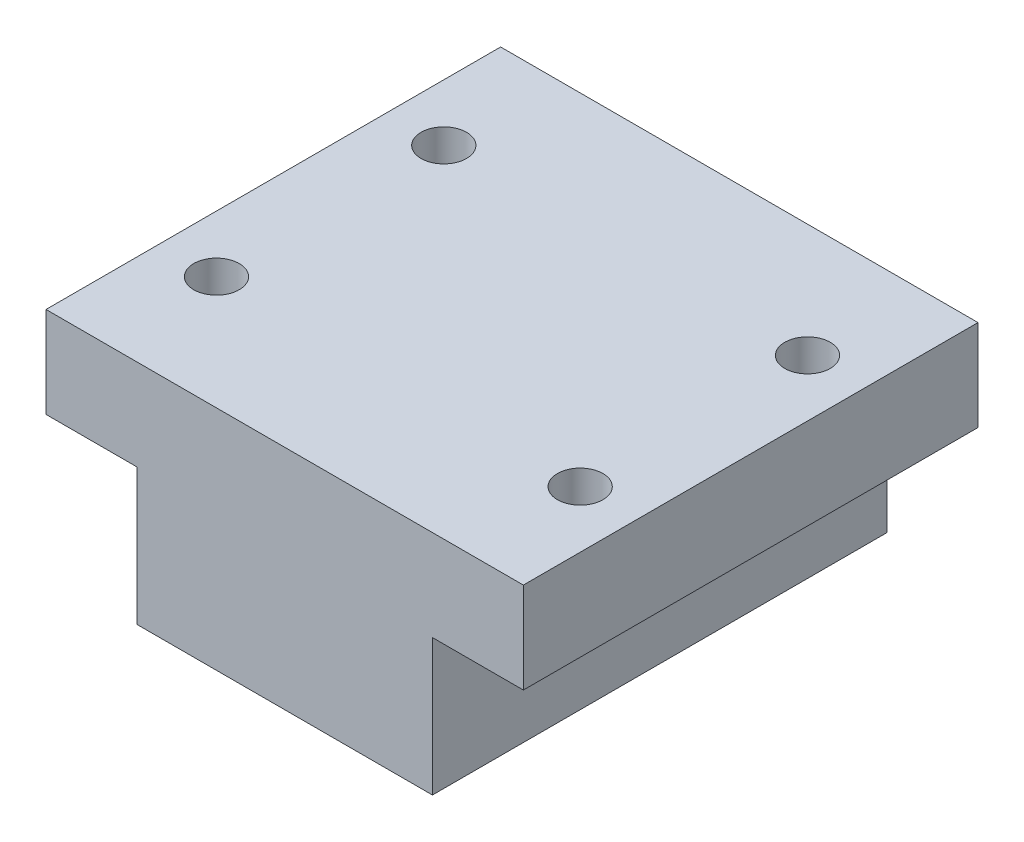
from build123d import *

# Parameters (mm, degrees)
BOSS_EXTRUDE1_DEPTH = 20
SKETCH2_R           = 2
CUT_EXTRUDE1_DEPTH  = 40
SKETCH4_R           = 5.5
CUT_EXTRUDE2_DEPTH  = 1.75


with BuildPart() as part:
    # Sketch1 → Boss-Extrude1 (new body, symmetric)
    with BuildSketch(Plane.XY):
        Polygon((13, -4), (21, -4), (21, 4), (-21, 4), (-21, -4), (-13, -4), (-13, -16), (13, -16), align=None)
    extrude(amount=BOSS_EXTRUDE1_DEPTH, both=True)

    # Sketch2 → Cut-Extrude1 (cut)
    with BuildSketch(Plane(origin=(0, 4, 0), x_dir=(1, 0, 0), z_dir=(0, 1, 0))):
        with Locations((-16, 10)):
            Circle(SKETCH2_R)
        with Locations((16, 10)):
            Circle(SKETCH2_R)
        with Locations((-16, -10)):
            Circle(SKETCH2_R)
        with Locations((16, -10)):
            Circle(SKETCH2_R)
    extrude(amount=-CUT_EXTRUDE1_DEPTH, mode=Mode.SUBTRACT)

    # Sketch4 → Cut-Extrude2 (cut)
    with BuildSketch(Plane.XZ.offset(16)):
        with Locations((0, -4.5)):
            Circle(SKETCH4_R)
    extrude(amount=-CUT_EXTRUDE2_DEPTH, mode=Mode.SUBTRACT)


solid = part.part
